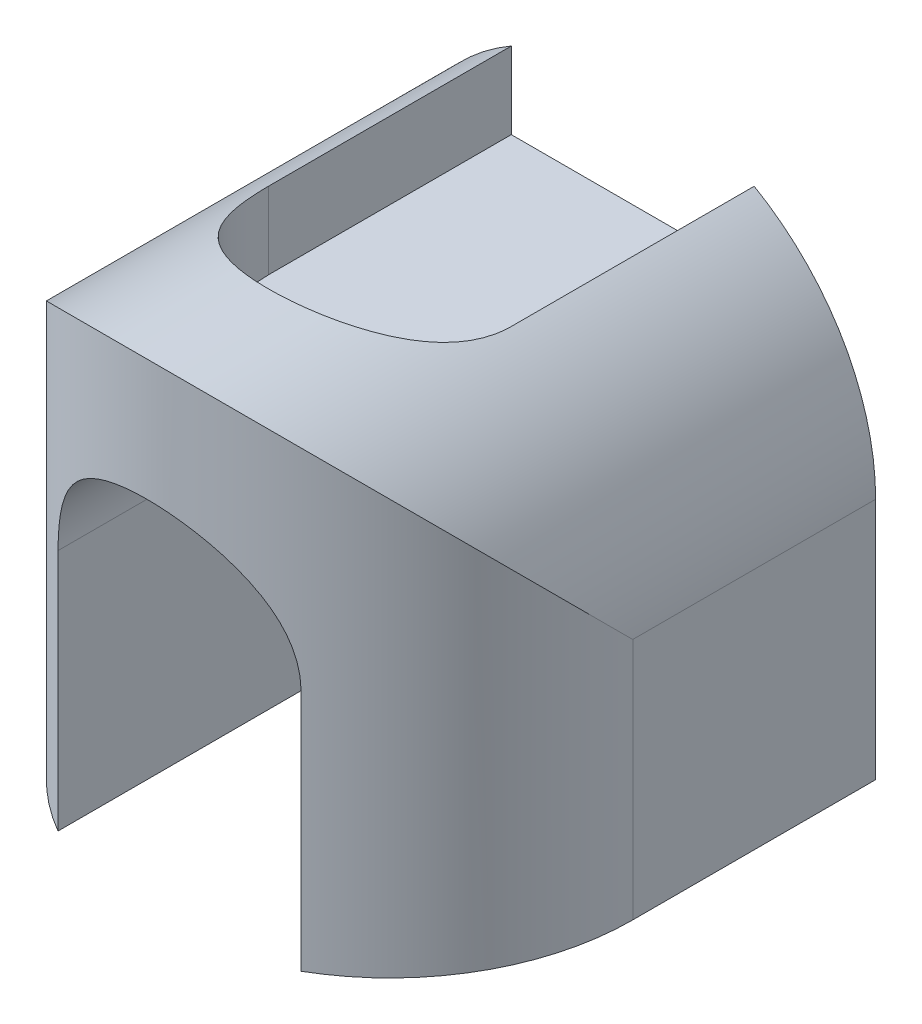
from build123d import *

# Parameters (mm, degrees)
BOSS_EXTRUDE2_DEPTH     = 40
SKETCH2_W               = 10
SKETCH2_H               = 40
BOSS_EXTRUDE3_DEPTH     = 20
CUT_EXTRUDE1_DEPTH      = 20
CUT_EXTRUDE1_DEPTH_BACK = 20
CUT_EXTRUDE4_DEPTH      = 51


with BuildPart() as part:
    # Sketch1 → Boss-Extrude2 (new body)
    with BuildSketch(Plane.XY):
        with BuildLine():
            ThreePointArc((20, 0), (0, 20), (-20, 0))
            Line((-20, 0), (-10, 0))
            ThreePointArc((-10, 0), (0, 10), (10, 0))
            Line((10, 0), (20, 0))
        make_face()
    extrude(amount=BOSS_EXTRUDE2_DEPTH)

    # Sketch2 → Boss-Extrude3 (add)
    with BuildSketch(Plane.XZ):
        with Locations((-15, 20)):
            Rectangle(SKETCH2_W, SKETCH2_H)
        with Locations((15, 20)):
            Rectangle(SKETCH2_W, SKETCH2_H)
    extrude(amount=BOSS_EXTRUDE3_DEPTH)

    # Sketch3 → Cut-Extrude1 (cut, two sides: drawn at the far end of the back side and taken through both)
    with BuildSketch(Plane(origin=(0, 0, 0), x_dir=(1, 0, 0), z_dir=(0, 1, 0)).offset(-CUT_EXTRUDE1_DEPTH_BACK)):
        with BuildLine():
            ThreePointArc((0, -40), (-14.142135624, -34.142135624), (-20, -20))
            Line((-20, -20), (-20, -40))
            Line((-20, -40), (0, -40))
        make_face()
        with BuildLine():
            ThreePointArc((20, -20), (14.142135624, -34.142135624), (0, -40))
            Line((0, -40), (20, -40))
            Line((20, -40), (20, -20))
        make_face()
    extrude(amount=CUT_EXTRUDE1_DEPTH + CUT_EXTRUDE1_DEPTH_BACK, mode=Mode.SUBTRACT)

    # Sketch6 → Cut-Extrude4 (cut)
    with BuildSketch(Plane(origin=(0, 11, 0), x_dir=(1, 0, 0), z_dir=(0, 1, 0))):
        with BuildLine():
            Line((-10, -20), (-10, 0))
            Line((-10, 0), (10, 0))
            Line((10, 0), (10, -20))
            ThreePointArc((10, -20), (0, -30), (-10, -20))
        make_face()
    extrude(amount=CUT_EXTRUDE4_DEPTH, mode=Mode.SUBTRACT)


solid = part.part
